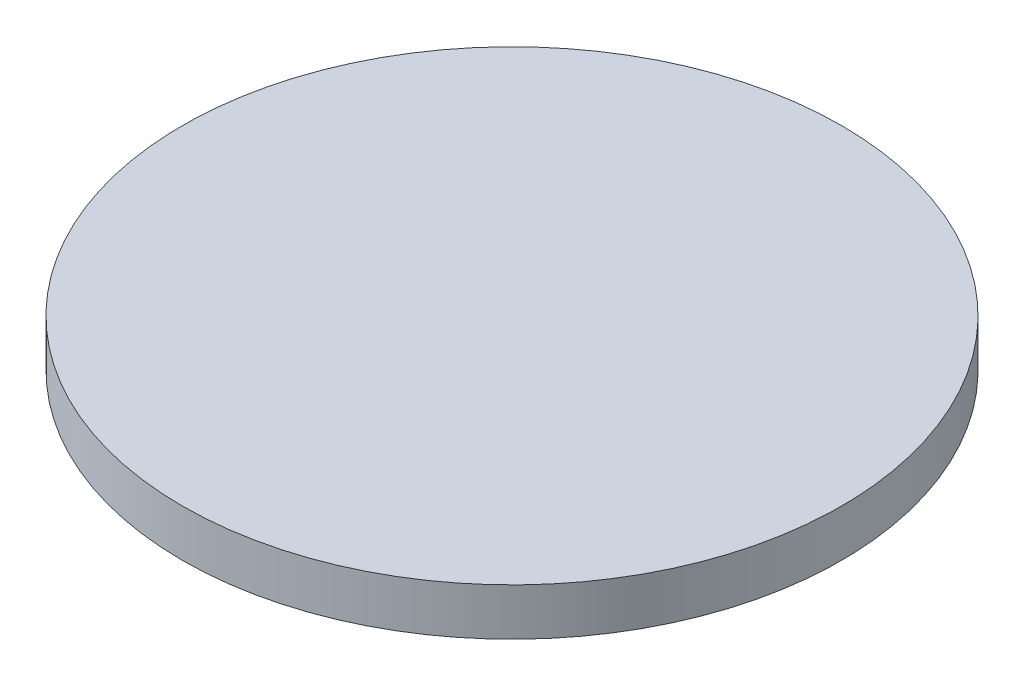
from build123d import *

# Parameters (mm, degrees)
SKETCH1_R           = 22.225
BOSS_EXTRUDE1_DEPTH = 3.175


with BuildPart() as part:
    # Sketch1 → Boss-Extrude1 (new body)
    with BuildSketch(Plane(origin=(0, 0, 0), x_dir=(1, 0, 0), z_dir=(0, 1, 0))):
        Circle(SKETCH1_R)
    extrude(amount=BOSS_EXTRUDE1_DEPTH)


solid = part.part
